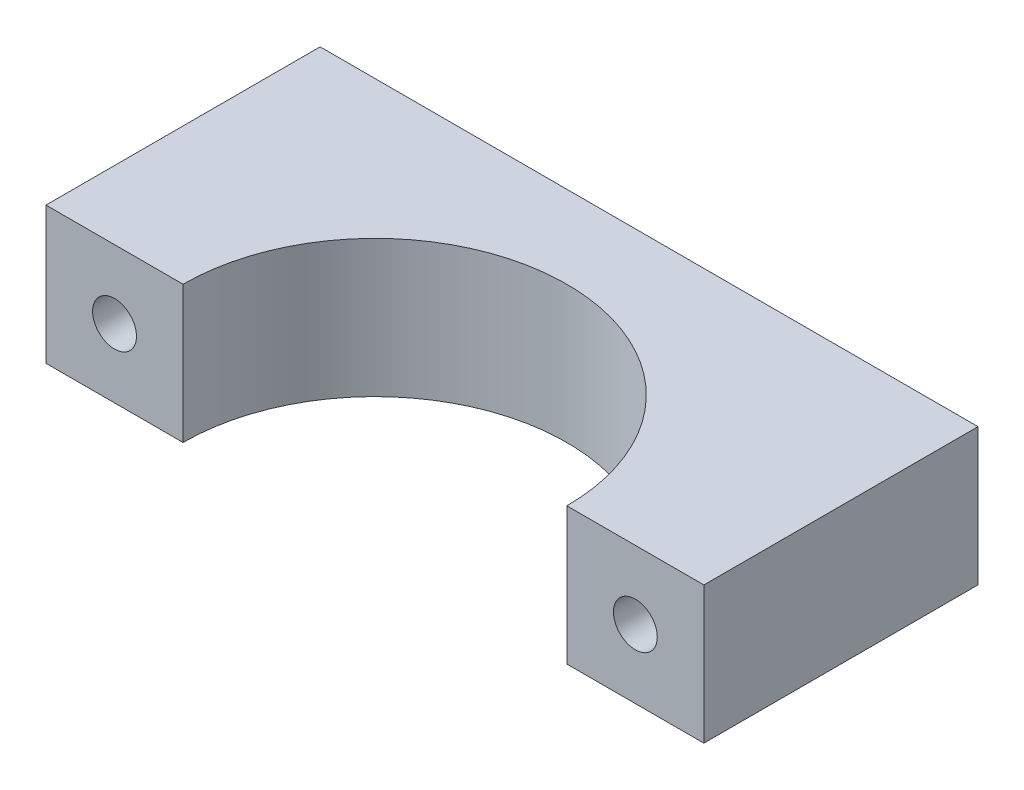
from build123d import *

# Parameters (mm, degrees)
AUFSATZ_LINEAR_AUSTRAGEN1_DEPTH = 10
SKIZZE2_R                       = 1.6
SCHNITT_LINEAR_AUSTRAGEN1_DEPTH = 21
SKIZZE3_R                       = 3
SCHNITT_LINEAR_AUSTRAGEN2_DEPTH = 13


with BuildPart() as part:
    # Skizze1 → Aufsatz-Linear austragen1 (new body)
    with BuildSketch(Plane(origin=(0, 0, 0), x_dir=(1, 0, 0), z_dir=(0, 1, 0))):
        with BuildLine():
            Line((14, -1), (24, -1))
            Line((24, -1), (24, 19))
            Line((24, 19), (-24, 19))
            Line((-24, 19), (-24, -1))
            Line((-24, -1), (-14, -1))
            ThreePointArc((-14, -1), (0, 13), (14, -1))
        make_face()
    extrude(amount=AUFSATZ_LINEAR_AUSTRAGEN1_DEPTH)

    # Skizze2 → Schnitt-Linear austragen1 (cut, through all)
    with BuildSketch(Plane.XY.offset(1)):
        with Locations((-19, 5)):
            Circle(SKIZZE2_R)
        with Locations((19, 5)):
            Circle(SKIZZE2_R)
    extrude(amount=-SCHNITT_LINEAR_AUSTRAGEN1_DEPTH, mode=Mode.SUBTRACT)

    # Skizze3 → Schnitt-Linear austragen2 (cut)
    with BuildSketch(Plane(origin=(0, 0, -19), x_dir=(-1, 0, 0), z_dir=(0, 0, -1))):
        with Locations((-19, 5)):
            Circle(SKIZZE3_R)
        with Locations((19, 5)):
            Circle(SKIZZE3_R)
    extrude(amount=-SCHNITT_LINEAR_AUSTRAGEN2_DEPTH, mode=Mode.SUBTRACT)


solid = part.part
